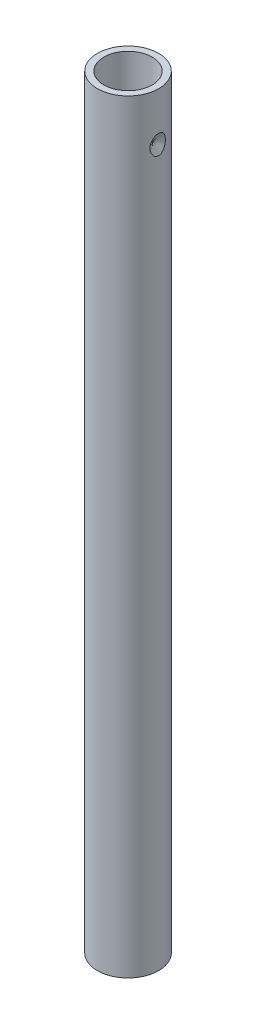
from build123d import *

# Parameters (mm, degrees)
SKETCH1_R           = 9.5
SKETCH1_R_2         = 7.5
EXTRUDE_THIN1_DEPTH = 237


with BuildPart() as part:
    # Sketch1 → Extrude-Thin1 (new body)
    with BuildSketch(Plane(origin=(0, 0, 0), x_dir=(1, 0, 0), z_dir=(0, 1, 0))):
        Circle(SKETCH1_R)
        Circle(SKETCH1_R_2, mode=Mode.SUBTRACT)
    extrude(amount=EXTRUDE_THIN1_DEPTH)

    # Sketch6 → Cut-Revolve1 (revolve, cut)
    with BuildSketch(Plane(origin=(0, 0, 0), x_dir=(0, 0, -1), z_dir=(1, 0, 0))):
        Polygon((8.5, 8), (9.5, 8), (9.5, 10), align=None)
    revolve(axis=Axis((0, 8, -0.902354342), (0, 0, -1)), mode=Mode.SUBTRACT)

    # Sketch10 → Cut-Revolve3 (revolve, cut)
    with BuildSketch(Plane.XY):
        Polygon((9.5, 222), (9.5, 225), (8, 222), align=None)
    revolve(axis=Axis((18.348289419, 222, 0), (-1, 0, 0)), mode=Mode.SUBTRACT)


solid = part.part
